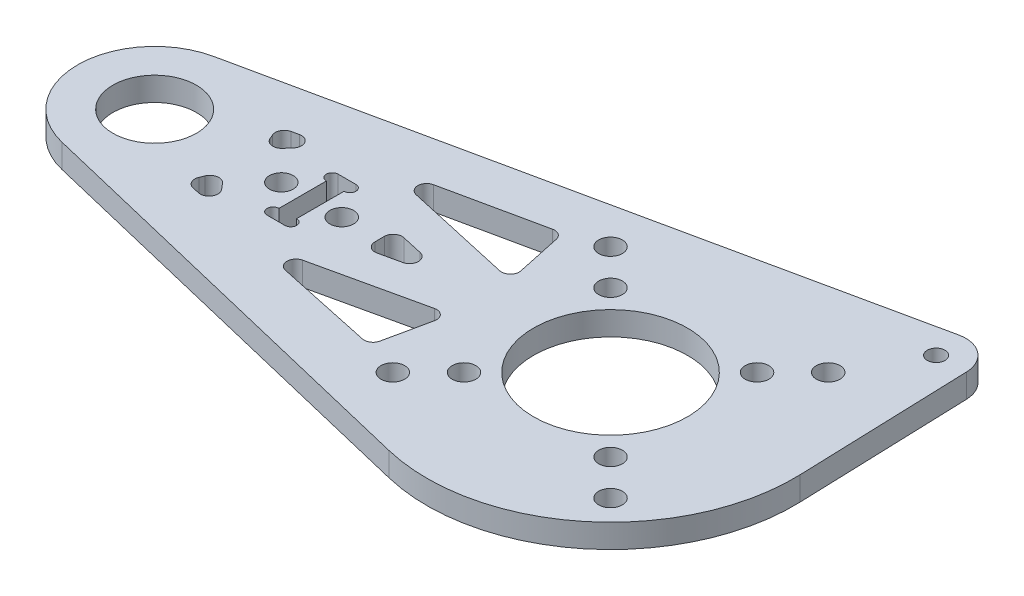
from build123d import *

# Parameters (mm, degrees)
SKETCH_1_R          = 7.05
SKETCH_1_R_2        = 1.5
SKETCH_1_R_3        = 2
SKETCH_1_R_4        = 13
EXTRUDE_1_DEPTH     = 4
SKETCH_4_R          = 2
SKETCH_4_W          = 3
SKETCH_4_H          = 12
CUT_EXTRUDE_7_DEPTH = 5
SKETCH_8_R          = 1
CUT_EXTRUDE_6_DEPTH = 5
CUT_EXTRUDE_8_DEPTH = 5
FILLET_1_R          = 1.5


with BuildPart() as part:
    # 草图1 → 凸台-拉伸1 (new body)
    with BuildSketch(Plane(origin=(0, 0, 0), x_dir=(1, 0, 0), z_dir=(0, 1, 0))):
        with BuildLine():
            Line((-79.719334557, 12.712404162), (23.954102093, 34.889386216))
            ThreePointArc((23.954102093, 34.889386216), (28.077901504, 33.940370837), (29.997141433, 30.169048806))
            Line((29.997141433, 30.169048806), (30.982276884, 1.048102596))
            ThreePointArc((30.982276884, 1.048102596), (19.5968113, -24.02009548), (-7.246753247, -30.141077741))
            Line((-7.246753247, -30.141077741), (-80.038961039, -12.639806795))
            ThreePointArc((-80.038961039, -12.639806795), (-89.998966964, 0.163883698), (-79.719334557, 12.712404162))
        make_face()
        with Locations((-77, 0)):
            Circle(SKETCH_1_R, mode=Mode.SUBTRACT)
        with Locations((25, 30)):
            Circle(SKETCH_1_R_2, mode=Mode.SUBTRACT)
        with Locations((-18.384776311, 18.384776311)):
            Circle(SKETCH_1_R_3, mode=Mode.SUBTRACT)
        with Locations((18.384776311, 18.384776311)):
            Circle(SKETCH_1_R_3, mode=Mode.SUBTRACT)
        with Locations((18.384776311, -18.384776311)):
            Circle(SKETCH_1_R_3, mode=Mode.SUBTRACT)
        with Locations((-18.384776311, -18.384776311)):
            Circle(SKETCH_1_R_3, mode=Mode.SUBTRACT)
        with Locations((-12.374368671, 12.374368671)):
            Circle(SKETCH_1_R_3, mode=Mode.SUBTRACT)
        with Locations((12.374368671, 12.374368671)):
            Circle(SKETCH_1_R_3, mode=Mode.SUBTRACT)
        with Locations((12.374368671, -12.374368671)):
            Circle(SKETCH_1_R_3, mode=Mode.SUBTRACT)
        with Locations((-12.374368671, -12.374368671)):
            Circle(SKETCH_1_R_3, mode=Mode.SUBTRACT)
        Circle(SKETCH_1_R_4, mode=Mode.SUBTRACT)
    extrude(amount=EXTRUDE_1_DEPTH)

    # 草图4 → 切除-拉伸7 (cut, through all)
    with BuildSketch(Plane(origin=(0, 4, 0), x_dir=(1, 0, 0), z_dir=(0, 1, 0))):
        with Locations((-55.6, 0)):
            Circle(SKETCH_4_R)
        with Locations((-45.4, 0)):
            Circle(SKETCH_4_R)
        with Locations((-50.5, 0)):
            Rectangle(SKETCH_4_W, SKETCH_4_H)
    extrude(amount=-CUT_EXTRUDE_7_DEPTH, mode=Mode.SUBTRACT)

    # 草图8 → 切除-拉伸6 (cut, through all)
    with BuildSketch(Plane(origin=(0, 4, 0), x_dir=(1, 0, 0), z_dir=(0, 1, 0))):
        with Locations((-52, 5)):
            Circle(SKETCH_8_R)
        with Locations((-52, -5)):
            Circle(SKETCH_8_R)
        with Locations((-49, -5)):
            Circle(SKETCH_8_R)
        with Locations((-49, 5)):
            Circle(SKETCH_8_R)
    extrude(amount=-CUT_EXTRUDE_6_DEPTH, mode=Mode.SUBTRACT)

    # 草图9 → 切除-拉伸8 (cut, through all)
    with BuildSketch(Plane(origin=(0, 4, 0), x_dir=(1, 0, 0), z_dir=(0, 1, 0))):
        Polygon((-24.369873114, 16.371326789), (-21.937410968, 5), (-49.115560904, 11.077929639), align=None)
        Polygon((-49.115560904, -11.077929639), (-24.369873114, -16.371326789), (-21.937410968, -5), align=None)
        with BuildLine():
            Line((-64.164776302, 7.858723345), (-56.703068356, 9.454871486))
            Line((-56.703068356, 9.454871486), (-62.252034039, 3))
            ThreePointArc((-62.252034039, 3), (-62.996076047, 5.512949656), (-64.164776302, 7.858723345))
        make_face()
        with BuildLine():
            Line((-56.703068356, -9.454871486), (-62.252034039, -3))
            ThreePointArc((-62.252034039, -3), (-62.996076047, -5.512949656), (-64.164776302, -7.858723345))
            Line((-64.164776302, -7.858723345), (-56.703068356, -9.454871486))
        make_face()
        Polygon((-39, 2.667552297), (-27.071738141, 0), (-39, -2.667552297), align=None)
    extrude(amount=-CUT_EXTRUDE_8_DEPTH, mode=Mode.SUBTRACT)

    # 圆角1
    fillet_1_edges = [part.edges().sort_by_distance(p)[0] for p in [
        (-49.115560904, 2, 11.077929639),
        (-21.937410968, 2, 5),
        (-24.369873114, 2, 16.371326789),
        (-62.252034039, 2, -3),
        (-64.164776302, 2, -7.858723345),
        (-56.703068356, 2, -9.454871486),
        (-39, 2, 2.667552297),
        (-39, 2, -2.667552297),
        (-27.071738141, 2, 0),
        (-64.164776302, 2, 7.858723345),
        (-62.252034039, 2, 3),
        (-56.703068356, 2, 9.454871486),
        (-49.115560904, 2, -11.077929639),
        (-24.369873114, 2, -16.371326789),
        (-21.937410968, 2, -5),
    ]]
    fillet(fillet_1_edges, radius=FILLET_1_R)


solid = part.part
